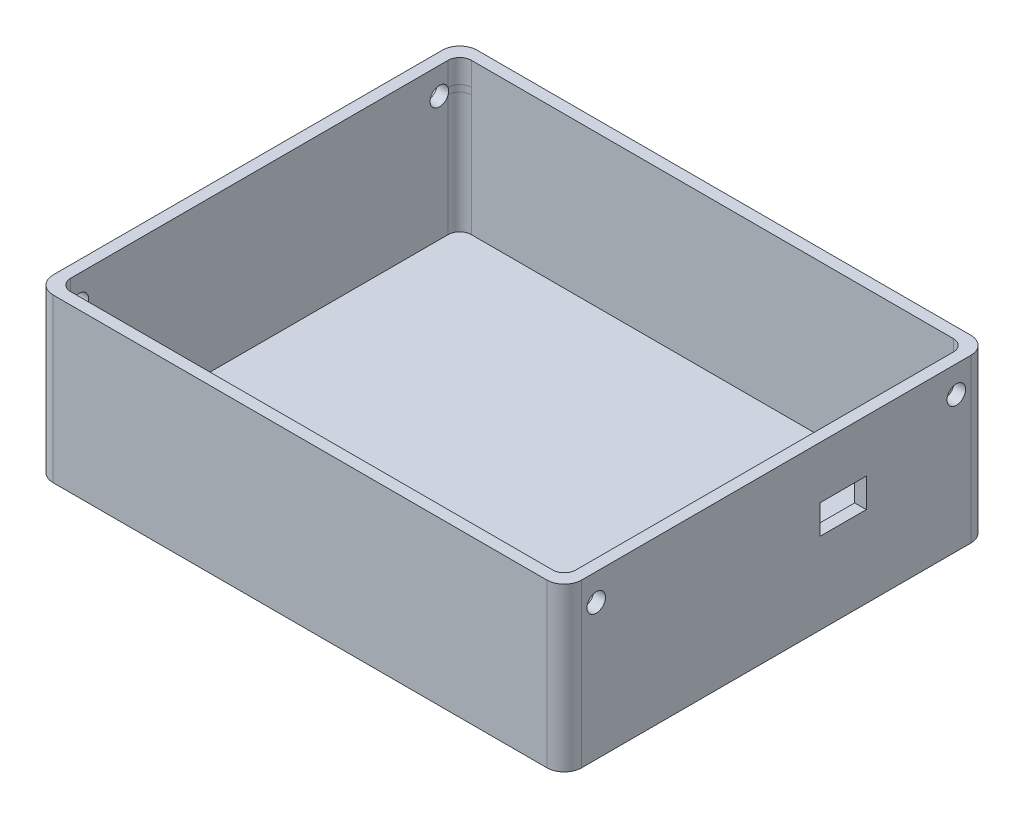
from build123d import *

# Parameters (mm, degrees)
SKETCH_1_W               = 91
SKETCH_1_H               = 73
EXTRUDE_1_DEPTH          = 28
SKETCH_2_W               = 87
SKETCH_2_H               = 69
CUT_EXTRUDE_1_DEPTH      = 26
SKETCH_3_W               = 8
SKETCH_3_H               = 5
CUT_EXTRUDE_2_DEPTH      = 26
SKETCH_4_R               = 1.6
CUT_EXTRUDE_5_DEPTH      = 4
MIRROR_2_COPY_1_SKETCH_R = 1.6
MIRROR_2_COPY_1_DEPTH    = 4
FILLET_2_R               = 3
FILLET_3_R               = 3
FILLET_4_R               = 3
FILLET_5_R               = 3
FILLET_6_R               = 2
FILLET_7_R               = 2
FILLET_8_R               = 2
FILLET_9_R               = 2


with BuildPart() as part:
    # 草图1 → 凸台-拉伸1 (new body)
    with BuildSketch(Plane(origin=(0, 0, 0), x_dir=(1, 0, 0), z_dir=(0, 1, 0))):
        Rectangle(SKETCH_1_W, SKETCH_1_H)
    extrude(amount=EXTRUDE_1_DEPTH)

    # 草图2 → 切除-拉伸1 (cut)
    with BuildSketch(Plane(origin=(0, 28, 0), x_dir=(1, 0, 0), z_dir=(0, 1, 0))):
        Rectangle(SKETCH_2_W, SKETCH_2_H)
    extrude(amount=-CUT_EXTRUDE_1_DEPTH, mode=Mode.SUBTRACT)

    # 草图3 → 切除-拉伸2 (cut)
    with BuildSketch(Plane.ZY.offset(-43.5)):
        with Locations((-11.5, 16.5)):
            Rectangle(SKETCH_3_W, SKETCH_3_H)
    extrude(amount=-CUT_EXTRUDE_2_DEPTH, mode=Mode.SUBTRACT)

    # 草图4 → 切除-拉伸5 (cut)
    with BuildSketch(Plane.ZY.offset(-43.5)):
        with Locations((31, 23.4)):
            Circle(SKETCH_4_R)
    cut_extrude_5 = extrude(amount=-CUT_EXTRUDE_5_DEPTH, mode=Mode.SUBTRACT)

    # 镜向1: 切除-拉伸5 across plane
    add(cut_extrude_5.mirror(Plane.XY), mode=Mode.SUBTRACT)

    # 镜向2: 切除-拉伸5 across plane
    add(cut_extrude_5.mirror(Plane(origin=(0, 0, 0), x_dir=(0, 0, 1), z_dir=(1, 0, 0))), mode=Mode.SUBTRACT)

    # 镜向2 copy 1 sketch → 镜向2 copy 1 (cut)
    with BuildSketch(Plane(origin=(-43.5, 0, 0), x_dir=(0, 0, -1), z_dir=(1, 0, 0))):
        with Locations((31, 23.4)):
            Circle(MIRROR_2_COPY_1_SKETCH_R)
    extrude(amount=-MIRROR_2_COPY_1_DEPTH, mode=Mode.SUBTRACT)

    # 圆角2
    fillet_2_edges = [part.edges().sort_by_distance(p)[0] for p in [
        (45.5, 14, 36.5),
    ]]
    fillet(fillet_2_edges, radius=FILLET_2_R)

    # 圆角3
    fillet_3_edges = [part.edges().sort_by_distance(p)[0] for p in [
        (-45.5, 14, 36.5),
    ]]
    fillet(fillet_3_edges, radius=FILLET_3_R)

    # 圆角4
    fillet_4_edges = [part.edges().sort_by_distance(p)[0] for p in [
        (-45.5, 14, -36.5),
    ]]
    fillet(fillet_4_edges, radius=FILLET_4_R)

    # 圆角5
    fillet_5_edges = [part.edges().sort_by_distance(p)[0] for p in [
        (45.5, 14, -36.5),
    ]]
    fillet(fillet_5_edges, radius=FILLET_5_R)

    # 圆角6
    fillet_6_edges = [part.edges().sort_by_distance(p)[0] for p in [
        (-43.5, 15, -34.5),
    ]]
    fillet(fillet_6_edges, radius=FILLET_6_R)

    # 圆角7
    fillet_7_edges = [part.edges().sort_by_distance(p)[0] for p in [
        (43.5, 15, -34.5),
    ]]
    fillet(fillet_7_edges, radius=FILLET_7_R)

    # 圆角8
    fillet_8_edges = [part.edges().sort_by_distance(p)[0] for p in [
        (-43.5, 15, 34.5),
    ]]
    fillet(fillet_8_edges, radius=FILLET_8_R)

    # 圆角9
    fillet_9_edges = [part.edges().sort_by_distance(p)[0] for p in [
        (43.5, 15, 34.5),
    ]]
    fillet(fillet_9_edges, radius=FILLET_9_R)


solid = part.part
